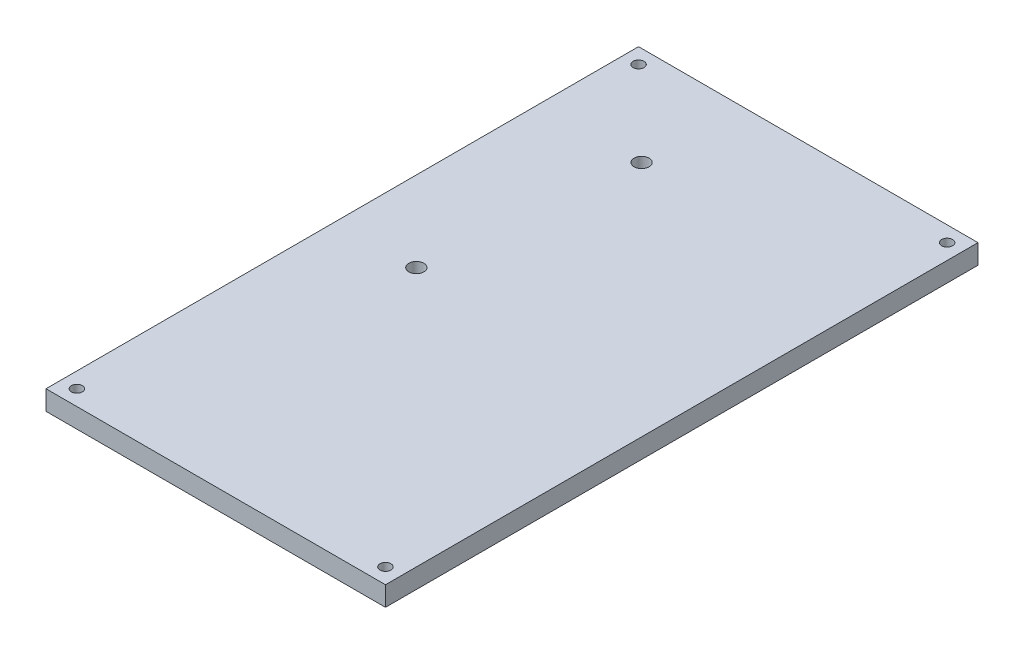
from build123d import *

# Parameters (mm, degrees)
SKETCH2_W             = 55
SKETCH2_H             = 96
BOSS_EXTRUDE1_DEPTH   = 3.175
F_2_CLEARANCE_HOLE1_D = 2.4384
F_0_CLEARANCE_HOLE1_D = 1.778


with BuildPart() as part:
    # Sketch2 → Boss-Extrude1 (new body)
    with BuildSketch(Plane(origin=(0, 0, 0), x_dir=(1, 0, 0), z_dir=(0, 1, 0))):
        with Locations((27.5, 48)):
            Rectangle(SKETCH2_W, SKETCH2_H)
    extrude(amount=BOSS_EXTRUDE1_DEPTH)

    # #2 Clearance Hole1 (through all)
    with Locations(Plane(origin=(0, 3.175, 0), x_dir=(1, 0, 0), z_dir=(0, 1, 0))):
        with Locations((16.5, 80), (13, 47)):
            Hole(F_2_CLEARANCE_HOLE1_D / 2)

    # #0 Clearance Hole1 (through all)
    with Locations(Plane(origin=(0, 3.175, 0), x_dir=(1, 0, 0), z_dir=(0, 1, 0))):
        with Locations((2.5, 2.5), (52.5, 2.5), (52.5, 93.5), (2.5, 93.5)):
            Hole(F_0_CLEARANCE_HOLE1_D / 2)


solid = part.part
